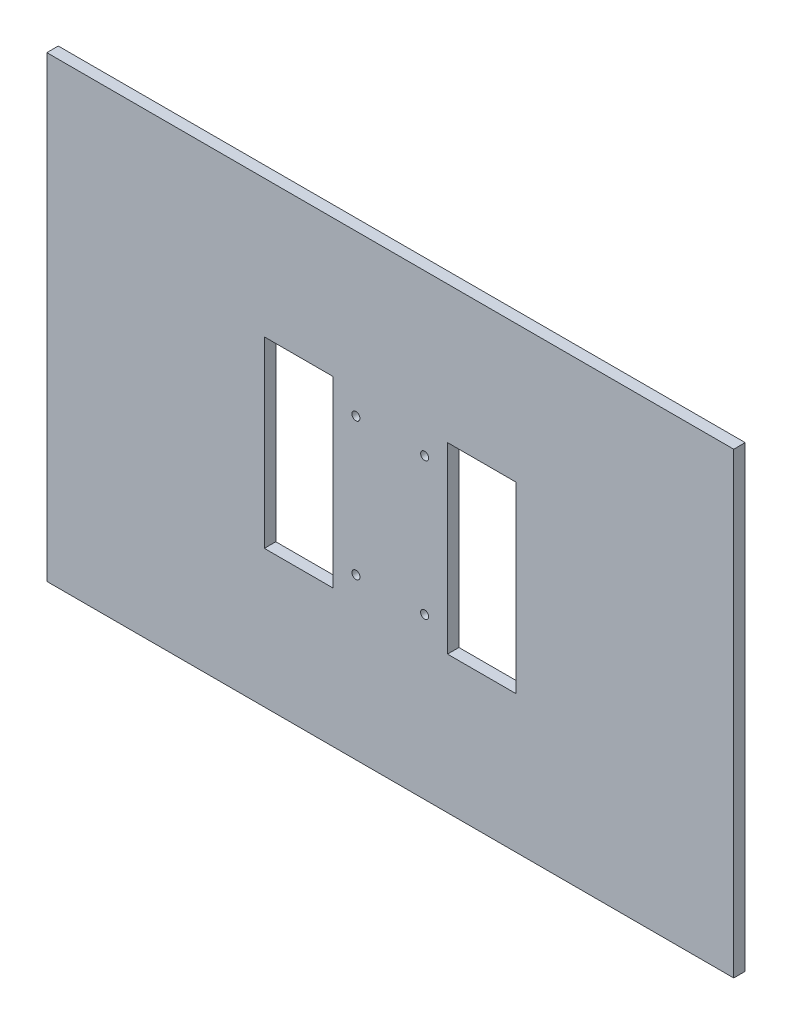
from build123d import *

# Parameters (mm, degrees)
SKETCH_1_W          = 300
SKETCH_1_H          = 200
EXTRUDE_1_DEPTH     = 5
SKETCH_2_R          = 1.75
SKETCH_2_W          = 30
SKETCH_2_H          = 80
CUT_EXTRUDE_1_DEPTH = 6


with BuildPart() as part:
    # ｽｹｯﾁ1 → ﾎﾞｽ - 押し出し1 (new body)
    with BuildSketch(Plane.XY):
        Rectangle(SKETCH_1_W, SKETCH_1_H)
    extrude(amount=EXTRUDE_1_DEPTH)

    # ｽｹｯﾁ2 → ｶｯﾄ - 押し出し1 (cut, through all)
    with BuildSketch(Plane.XY.offset(5)):
        with Locations((15, 30)):
            Circle(SKETCH_2_R)
        with Locations((-15, 30)):
            Circle(SKETCH_2_R)
        with Locations((-15, -30)):
            Circle(SKETCH_2_R)
        with Locations((15, -30)):
            Circle(SKETCH_2_R)
        with Locations((40, 0)):
            Rectangle(SKETCH_2_W, SKETCH_2_H)
        with Locations((-40, 0)):
            Rectangle(SKETCH_2_W, SKETCH_2_H)
    extrude(amount=-CUT_EXTRUDE_1_DEPTH, mode=Mode.SUBTRACT)


solid = part.part
